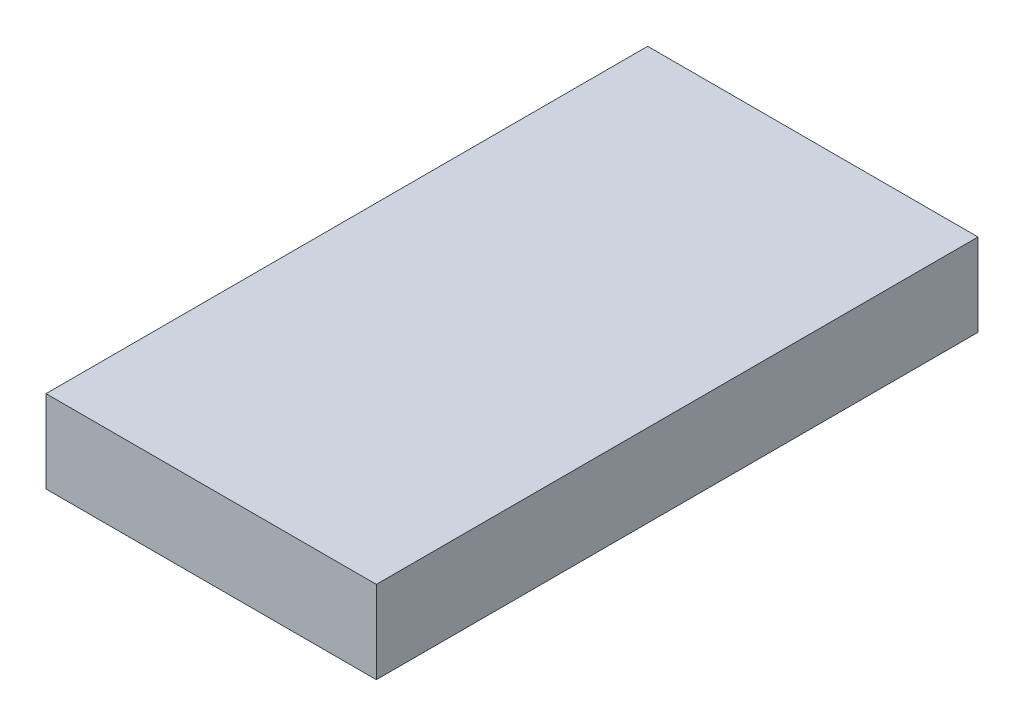
from build123d import *

# Parameters (mm, degrees)
SKETCH1_W           = 112
SKETCH1_H           = 28
BOSS_EXTRUDE2_DEPTH = 204


with BuildPart() as part:
    # Sketch1 → Boss-Extrude2 (new body)
    with BuildSketch(Plane.XY):
        Rectangle(SKETCH1_W, SKETCH1_H)
    extrude(amount=-BOSS_EXTRUDE2_DEPTH)


solid = part.part
